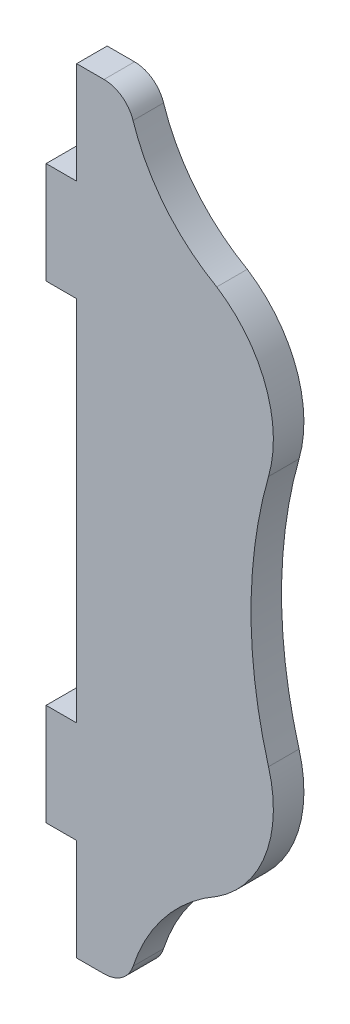
from build123d import *

# Parameters (mm, degrees)
SALIENTE_EXTRUIR1_DEPTH = 3


with BuildPart() as part:
    # Model → Saliente-Extruir1 (new body)
    with BuildSketch(Plane.XY):
        with BuildLine():
            Line((25.488716275, 56.424131461), (28.178792169, 56.424131461))
            ThreePointArc((28.178792169, 56.424131461), (29.940174662, 55.85261488), (31.030450954, 54.355819272))
            ThreePointArc((31.030450954, 54.355819272), (34.201179997, 48.563621322), (39.252486332, 44.310694794))
            ThreePointArc((39.252486332, 44.310694794), (44.045367232, 38.357656573), (44.338099173, 30.720596968))
            ThreePointArc((44.338099173, 30.720596968), (42.619326371, 18.377856), (44.338099173, 6.035115032))
            ThreePointArc((44.338099173, 6.035115032), (44.045367232, -1.601944573), (39.252486332, -7.554982794))
            ThreePointArc((39.252486332, -7.554982794), (34.201179997, -11.807909322), (31.030450954, -17.600107272))
            ThreePointArc((31.030450954, -17.600107272), (29.940174662, -19.09690288), (28.178792169, -19.668419461))
            Line((28.178792169, -19.668419461), (25.488716275, -19.668419461))
            Line((25.488716275, -19.668419461), (25.488716275, -9.668419461))
            Line((25.488716275, -9.668419461), (22.488716275, -9.668419461))
            Line((22.488716275, -9.668419461), (22.488716275, 0.331580539))
            Line((22.488716275, 0.331580539), (25.488716275, 0.331580539))
            Line((25.488716275, 0.331580539), (25.488716275, 36.424131461))
            Line((25.488716275, 36.424131461), (22.488716275, 36.424131461))
            Line((22.488716275, 36.424131461), (22.488716275, 46.424131461))
            Line((22.488716275, 46.424131461), (25.488716275, 46.424131461))
            Line((25.488716275, 46.424131461), (25.488716275, 56.424131461))
        make_face()
    extrude(amount=SALIENTE_EXTRUIR1_DEPTH)


solid = part.part
